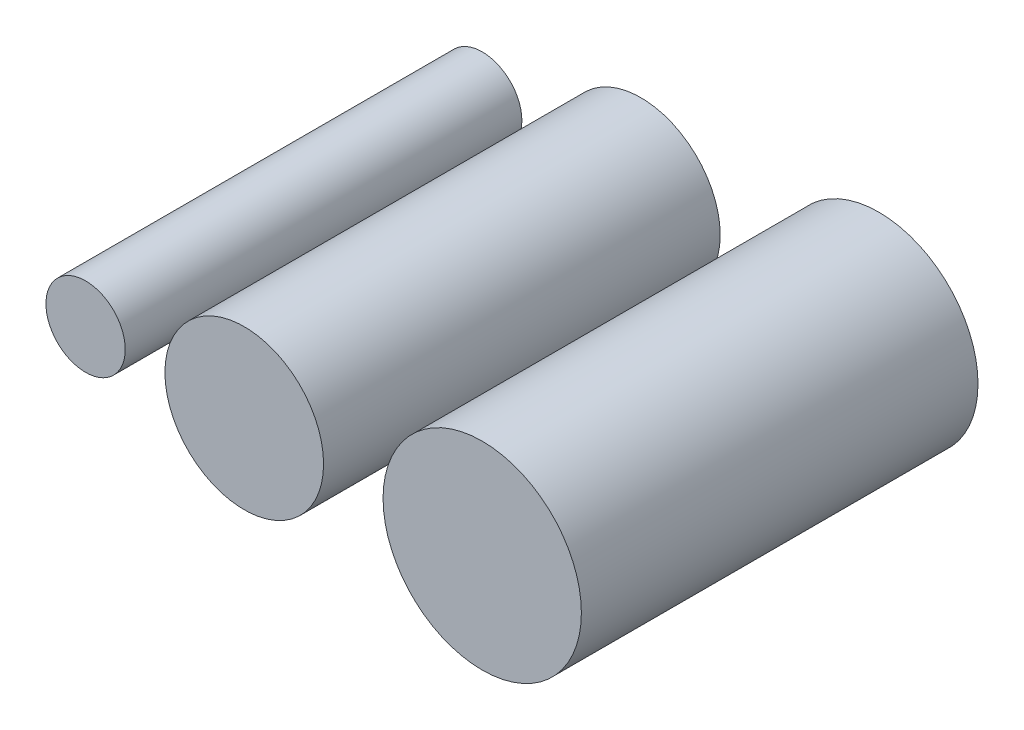
from build123d import *

# Parameters (mm, degrees)
SKETCH1_R             = 0.5
BOSS_EXTRUDE1_DEPTH   = 5
SKETCH1_R_2           = 1
BOSS_EXTRUDE1_2_DEPTH = 5
SKETCH1_R_3           = 1.25
BOSS_EXTRUDE1_3_DEPTH = 5


with BuildPart() as part:
    # Sketch1 → Boss-Extrude1 (new body)
    with BuildSketch(Plane.XY):
        Circle(SKETCH1_R)
    extrude(amount=BOSS_EXTRUDE1_DEPTH)


with BuildPart() as body_2:
    # Sketch1 → Boss-Extrude1 2 (new body)
    with BuildSketch(Plane.XY):
        with Locations((2, 0)):
            Circle(SKETCH1_R_2)
    extrude(amount=BOSS_EXTRUDE1_2_DEPTH)


with BuildPart() as body_3:
    # Sketch1 → Boss-Extrude1 3 (new body)
    with BuildSketch(Plane.XY):
        with Locations((5, 0)):
            Circle(SKETCH1_R_3)
    extrude(amount=BOSS_EXTRUDE1_3_DEPTH)


solid = Compound([part.part, body_2.part, body_3.part])
